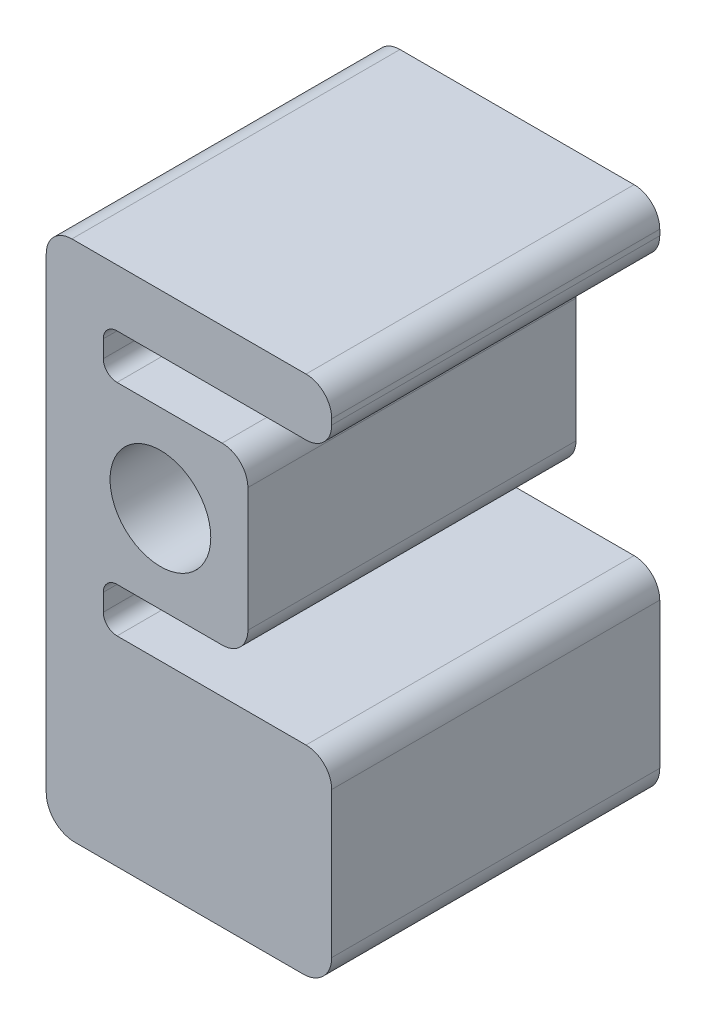
from build123d import *

# Parameters (mm, degrees)
SKETCH1_R           = 11.2
BOSS_EXTRUDE1_DEPTH = 72.971741788


with BuildPart() as part:
    # Sketch1 → Boss-Extrude1 (new body)
    with BuildSketch(Plane.XY):
        with BuildLine():
            Line((-25.4, -67.479999962), (-25.4, 36.365))
            ThreePointArc((-25.4, 36.365), (-23.726115254, 40.406115254), (-19.685, 42.08))
            Line((-19.685, 42.08), (32.385, 42.08))
            ThreePointArc((32.385, 42.08), (36.426115254, 40.406115254), (38.1, 36.365))
            Line((38.1, 36.365), (38.1, 35.095))
            ThreePointArc((38.1, 35.095), (36.426115254, 31.053884746), (32.385, 29.38))
            Line((32.385, 29.38), (-9.652, 29.38))
            ThreePointArc((-9.652, 29.38), (-11.807261469, 28.487261469), (-12.7, 26.332))
            Line((-12.7, 26.332), (-12.7, 22.503))
            ThreePointArc((-12.7, 22.503), (-11.807261469, 20.347738531), (-9.652, 19.455))
            Line((-9.652, 19.455), (0, 19.455))
            Line((0, 19.455), (13.74, 19.455))
            ThreePointArc((13.74, 19.455), (17.781115254, 17.781115254), (19.455, 13.74))
            Line((19.455, 13.74), (19.455, 0))
            Line((19.455, 0), (19.455, -13.74))
            ThreePointArc((19.455, -13.74), (17.781115254, -17.781115254), (13.74, -19.455))
            Line((13.74, -19.455), (0, -19.455))
            Line((0, -19.455), (-9.652, -19.455))
            ThreePointArc((-9.652, -19.455), (-11.807261469, -20.347738531), (-12.7, -22.503))
            Line((-12.7, -22.503), (-12.7, -26.331999962))
            ThreePointArc((-12.7, -26.331999962), (-11.807261469, -28.487261431), (-9.652, -29.379999962))
            Line((-9.652, -29.379999962), (32.385, -29.379999962))
            ThreePointArc((32.385, -29.379999962), (36.426115254, -31.053884708), (38.1, -35.094999962))
            Line((38.1, -35.094999962), (38.1, -67.479999962))
            ThreePointArc((38.1, -67.479999962), (36.240128061, -71.970128023), (31.75, -73.829999962))
            Line((31.75, -73.829999962), (-19.05, -73.829999962))
            ThreePointArc((-19.05, -73.829999962), (-23.540128061, -71.970128023), (-25.4, -67.479999962))
        make_face()
        Circle(SKETCH1_R, mode=Mode.SUBTRACT)
    extrude(amount=BOSS_EXTRUDE1_DEPTH)


solid = part.part
